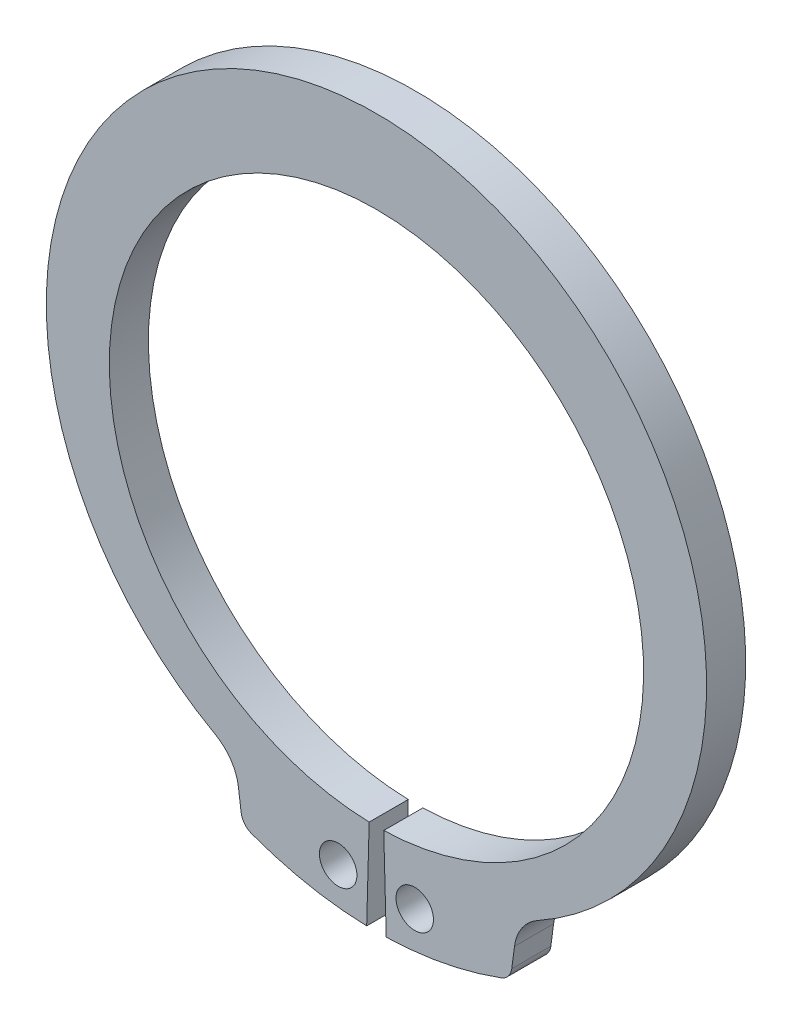
from build123d import *

# Parameters (mm, degrees)
BODYSKE_R  = 1.15
BODY_DEPTH = 2.4


with BuildPart() as part:
    # BodySke → Body (new body)
    with BuildSketch(Plane.XY):
        with BuildLine():
            Line((0.447272727, -16.393899692), (0.6, -21.99181666))
            ThreePointArc((0.6, -21.99181666), (4.187980739, -21.597703983), (7.663224061, -20.622196706))
            ThreePointArc((7.663224061, -20.622196706), (8.096879292, -20.308123136), (8.306340556, -19.815350321))
            Line((8.306340556, -19.815350321), (8.474068203, -18.541332355))
            ThreePointArc((8.474068203, -18.541332355), (8.932899586, -17.33524232), (9.884063974, -16.463195465))
            ThreePointArc((9.884063974, -16.463195465), (0, 21.5), (-9.884063974, -16.463195465))
            ThreePointArc((-9.884063974, -16.463195465), (-8.932899586, -17.33524232), (-8.474068203, -18.541332355))
            Line((-8.474068203, -18.541332355), (-8.306340556, -19.815350321))
            ThreePointArc((-8.306340556, -19.815350321), (-8.096879292, -20.308123136), (-7.663224061, -20.622196706))
            ThreePointArc((-7.663224061, -20.622196706), (-4.187980739, -21.597703983), (-0.6, -21.99181666))
            Line((-0.6, -21.99181666), (-0.447272727, -16.393899692))
            ThreePointArc((-0.447272727, -16.393899692), (0, 16.4), (0.447272727, -16.393899692))
        make_face()
        with Locations((2.35, -19.609691482)):
            Circle(BODYSKE_R, mode=Mode.SUBTRACT)
        with Locations((-2.35, -19.609691482)):
            Circle(BODYSKE_R, mode=Mode.SUBTRACT)
    extrude(amount=-BODY_DEPTH)


solid = part.part
